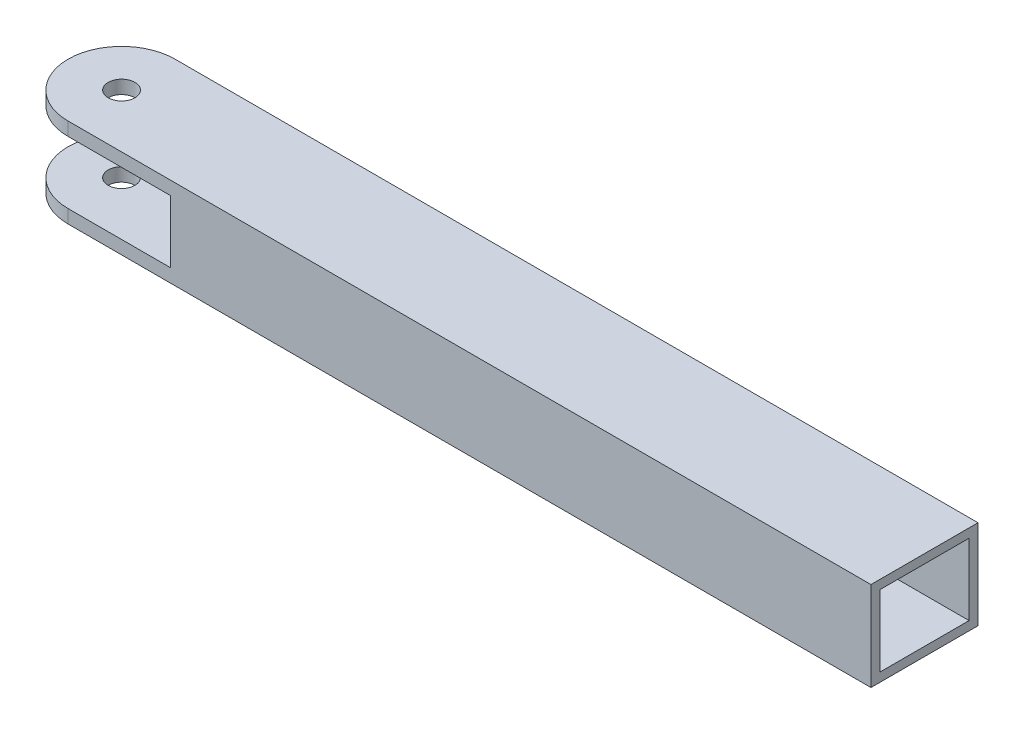
from build123d import *

# Parameters (mm, degrees)
SZKIC1_R                    = 1.5
DODANIE_WYCI_GNI_CIE1_DEPTH = 10
SZKIC2_W                    = 35
SZKIC2_H                    = 7
WYTNIJ_WYCI_GNI_CIE1_DEPTH  = 13
SZKIC3_W                    = 10
SZKIC3_H                    = 8
WYTNIJ_WYCI_GNI_CIE2_DEPTH  = 75


with BuildPart() as part:
    # Szkic1 → Dodanie-wyciągnięcie1 (new body)
    with BuildSketch(Plane(origin=(0, 0, 0), x_dir=(1, 0, 0), z_dir=(0, 1, 0))):
        with BuildLine():
            Line((0, 6), (90, 6))
            Line((90, 6), (90, -6))
            Line((90, -6), (0, -6))
            ThreePointArc((0, -6), (-6, 0), (0, 6))
        make_face()
        Circle(SZKIC1_R, mode=Mode.SUBTRACT)
    extrude(amount=DODANIE_WYCI_GNI_CIE1_DEPTH)

    # Szkic2 → Wytnij-wyciągnięcie1 (cut, through all)
    with BuildSketch(Plane(origin=(0, 0, -6), x_dir=(-1, 0, 0), z_dir=(0, 0, -1))):
        with Locations((6, 5)):
            Rectangle(SZKIC2_W, SZKIC2_H)
    extrude(amount=-WYTNIJ_WYCI_GNI_CIE1_DEPTH, mode=Mode.SUBTRACT)

    # Szkic3 → Wytnij-wyciągnięcie2 (cut)
    with BuildSketch(Plane(origin=(90, 0, 0), x_dir=(0, 0, -1), z_dir=(1, 0, 0))):
        with Locations((0, 5)):
            Rectangle(SZKIC3_W, SZKIC3_H)
    extrude(amount=-WYTNIJ_WYCI_GNI_CIE2_DEPTH, mode=Mode.SUBTRACT)


solid = part.part
